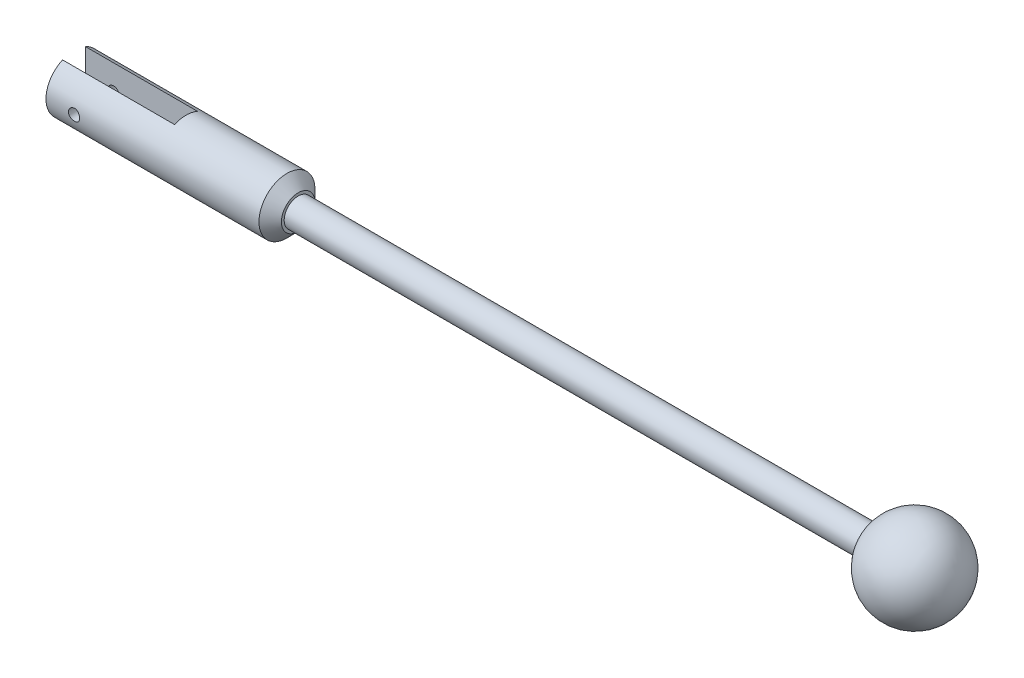
from build123d import *

# Parameters (mm, degrees)
SKETCH1_W               = 75
SKETCH1_H               = 1.25
SKETCH2_R               = 2.5
BOSS_EXTRUDE1_DEPTH     = 20
SKETCH3_W               = 2.05
SKETCH3_H               = 5
CUT_EXTRUDE1_DEPTH      = 1
CUT_EXTRUDE1_DEPTH_BACK = 10
CHAMFER1_SIZE           = 1
SKETCH4_R               = 0.5
CUT_EXTRUDE2_DEPTH      = 4.525
CUT_EXTRUDE2_DEPTH_BACK = 2.475


with BuildPart() as part:
    # Sketch1 → Revolve2 (revolve)
    with BuildSketch(Plane(origin=(0, 0, 0), x_dir=(1, 0, 0), z_dir=(0, 1, 0))):
        with Locations((0, -0.625)):
            Rectangle(SKETCH1_W, SKETCH1_H)
    revolve(axis=Axis((-37.5, 0, 0), (1, 0, 0)))

    # Sketch2 → Boss-Extrude1 (add)
    with BuildSketch(Plane.ZY.offset(37.5)):
        Circle(SKETCH2_R)
    extrude(amount=-BOSS_EXTRUDE1_DEPTH)

    # Sketch3 → Cut-Extrude1 (cut, two sides)
    with BuildSketch(Plane.ZY.offset(37.5)) as cut_extrude1_sk:
        Rectangle(SKETCH3_W, SKETCH3_H)
    extrude(amount=CUT_EXTRUDE1_DEPTH, mode=Mode.SUBTRACT)
    extrude(cut_extrude1_sk.sketch, amount=-CUT_EXTRUDE1_DEPTH_BACK, mode=Mode.SUBTRACT)

    # Chamfer1
    chamfer1_edges = [part.edges().sort_by_distance(p)[0] for p in [
        (-17.5, 0, -2.5),
    ]]
    chamfer(chamfer1_edges, length=CHAMFER1_SIZE)

    # Sketch4 → Cut-Extrude2 (cut, two sides)
    with BuildSketch(Plane.XY.offset(-1.025)) as cut_extrude2_sk:
        with Locations((-35, 0)):
            Circle(SKETCH4_R)
    extrude(amount=CUT_EXTRUDE2_DEPTH, mode=Mode.SUBTRACT)
    extrude(cut_extrude2_sk.sketch, amount=-CUT_EXTRUDE2_DEPTH_BACK, mode=Mode.SUBTRACT)

    # Sketch5 one side → Revolve3 (revolve)
    with BuildSketch(Plane(origin=(37.5, 0, 0), x_dir=(0, 0, -1), z_dir=(1, 0, 0))):
        with BuildLine():
            ThreePointArc((1.25, 0), (0, 1.25), (-1.25, 0))
            Line((-1.25, 0), (1.25, 0))
        make_face()
        with BuildLine():
            Line((-4, 0), (-1.25, 0))
            ThreePointArc((-1.25, 0), (0, 1.25), (1.25, 0))
            Line((1.25, 0), (4, 0))
            ThreePointArc((4, 0), (0, 4), (-4, 0))
        make_face()
    revolve(axis=Axis((37.5, 0, 4), (0, 0, -1)))


solid = part.part
